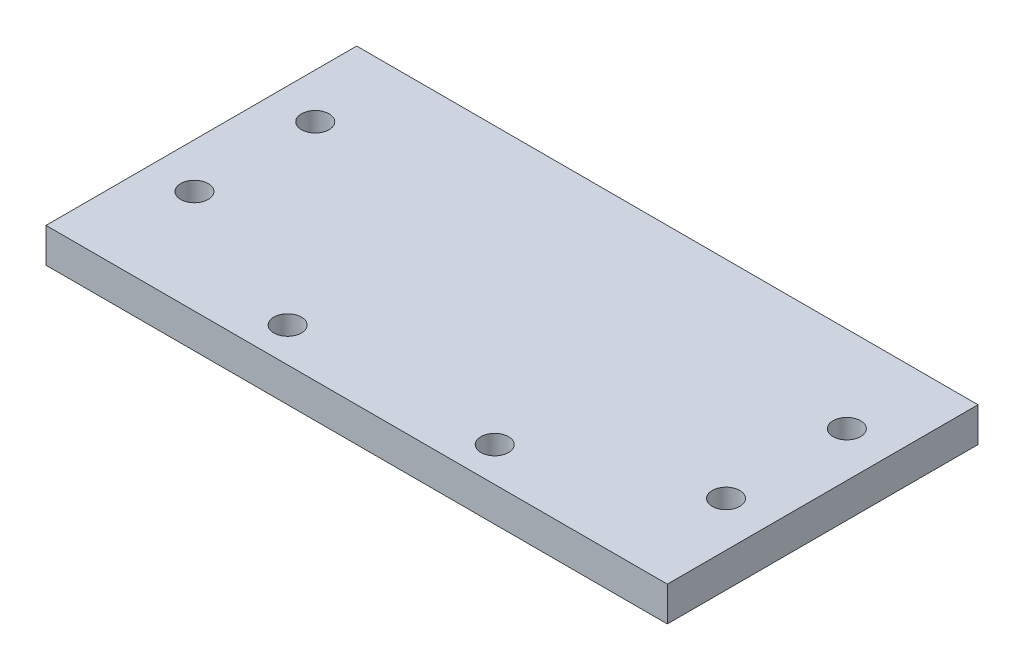
from build123d import *

# Parameters (mm, degrees)
SKETCH1_W           = 180
SKETCH1_H           = 90
SKETCH1_R           = 4
BOSS_EXTRUDE1_DEPTH = 10


with BuildPart() as part:
    # Sketch1 → Boss-Extrude1 (new body)
    with BuildSketch(Plane(origin=(0, 0, 0), x_dir=(1, 0, 0), z_dir=(0, 1, 0))):
        Rectangle(SKETCH1_W, SKETCH1_H)
        with Locations((-77, 20)):
            Circle(SKETCH1_R, mode=Mode.SUBTRACT)
        with Locations((-77, -15)):
            Circle(SKETCH1_R, mode=Mode.SUBTRACT)
        with Locations((-30, -35)):
            Circle(SKETCH1_R, mode=Mode.SUBTRACT)
        with Locations((77, 20)):
            Circle(SKETCH1_R, mode=Mode.SUBTRACT)
        with Locations((77, -15)):
            Circle(SKETCH1_R, mode=Mode.SUBTRACT)
        with Locations((30, -35)):
            Circle(SKETCH1_R, mode=Mode.SUBTRACT)
    extrude(amount=BOSS_EXTRUDE1_DEPTH)


solid = part.part
